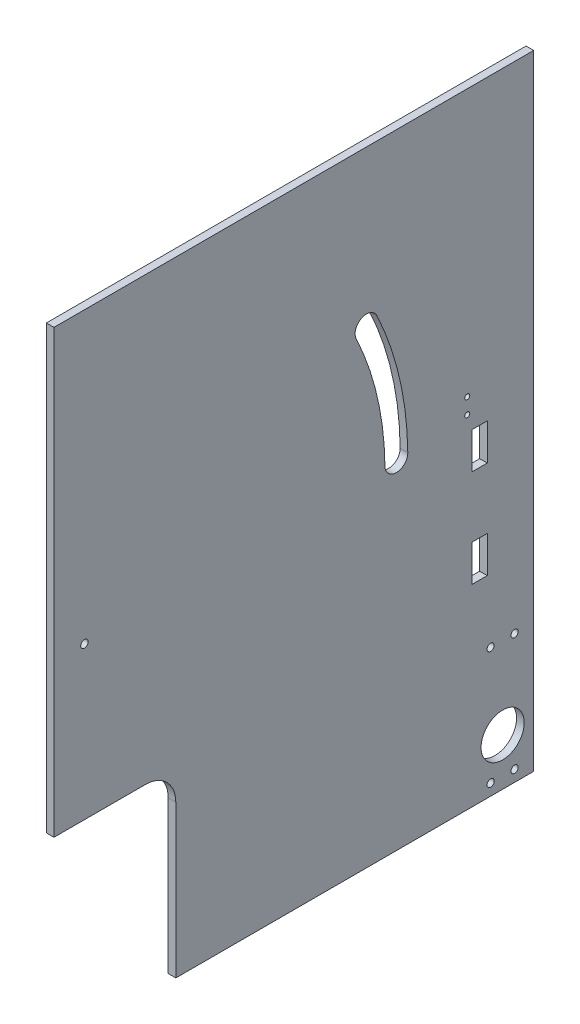
from build123d import *

# Parameters (mm, degrees)
SKETCH1_W           = 200.025
SKETCH1_H           = 260.35
BOSS_EXTRUDE1_DEPTH = 3.175
SKETCH8_R           = 1.55
SKETCH8_R_2         = 1.0499979
CUT_EXTRUDE7_DEPTH  = 4.175
SKETCH9_W           = 50.8
SKETCH9_H           = 76.2
CUT_EXTRUDE8_DEPTH  = 4.175
FILLET1_R           = 12.7
CUT_EXTRUDE9_DEPTH  = 4.175
SKETCH15_W          = 6.35
SKETCH15_H          = 15.24
CUT_EXTRUDE12_DEPTH = 4.175
SKETCH16_R          = 1.5
SKETCH16_R_2        = 9
CUT_EXTRUDE13_DEPTH = 4.175


with BuildPart() as part:
    # Sketch1 → Boss-Extrude1 (new body)
    with BuildSketch(Plane(origin=(0, 0, 0), x_dir=(0, 0, -1), z_dir=(1, 0, 0))):
        Rectangle(SKETCH1_W, SKETCH1_H)
    extrude(amount=BOSS_EXTRUDE1_DEPTH)

    # Sketch8 → Cut-Extrude7 (cut, through all)
    with BuildSketch(Plane.ZY):
        with Locations((87.3125, 9.525)):
            Circle(SKETCH8_R)
        with Locations((-72.3175, 18.9250066)):
            Circle(SKETCH8_R_2)
        with Locations((-72.3175, 12.4249942)):
            Circle(SKETCH8_R_2)
    extrude(amount=-CUT_EXTRUDE7_DEPTH, mode=Mode.SUBTRACT)

    # Sketch9 → Cut-Extrude8 (cut, through all)
    with BuildSketch(Plane.ZY):
        with Locations((74.6125, -92.075)):
            Rectangle(SKETCH9_W, SKETCH9_H)
    extrude(amount=-CUT_EXTRUDE8_DEPTH, mode=Mode.SUBTRACT)

    # Fillet1
    fillet1_edges = [part.edges().sort_by_distance(p)[0] for p in [
        (1.5875, -53.975, 49.2125),
    ]]
    fillet(fillet1_edges, radius=FILLET1_R)

    # Sketch10 → Cut-Extrude9 (cut, through all)
    with BuildSketch(Plane.ZY):
        with BuildLine():
            ThreePointArc((-34.631218673, 67.095364965), (-44.09213985, 39.8142402), (-47.528128749, 11.144346963))
            ThreePointArc((-47.528128749, 11.144346963), (-42.823162504, 6.325000001), (-38.003815542, 11.029966247))
            ThreePointArc((-38.003815542, 11.029966247), (-34.810523806, 37.674794334), (-26.017864022, 63.028948034))
            ThreePointArc((-26.017864022, 63.028948034), (-28.291332832, 69.36883393), (-34.631218673, 67.095364965))
        make_face()
    extrude(amount=-CUT_EXTRUDE9_DEPTH, mode=Mode.SUBTRACT)

    # Sketch15 → Cut-Extrude12 (cut, through all)
    with BuildSketch(Plane(origin=(3.175, 0, 0), x_dir=(0, 0, -1), z_dir=(1, 0, 0))):
        with Locations((77.4925, -1.5450058)):
            Rectangle(SKETCH15_W, SKETCH15_H)
        with Locations((77.4925, -42.1850058)):
            Rectangle(SKETCH15_W, SKETCH15_H)
    extrude(amount=-CUT_EXTRUDE12_DEPTH, mode=Mode.SUBTRACT)

    # Sketch16 → Cut-Extrude13 (cut, through all)
    with BuildSketch(Plane(origin=(3.175, 0, 0), x_dir=(0, 0, -1), z_dir=(1, 0, 0))):
        with Locations((82.075, -125.4125)):
            Circle(SKETCH16_R)
        with Locations((82.075, -76.4125)):
            Circle(SKETCH16_R)
        with Locations((92.075, -125.4125)):
            Circle(SKETCH16_R)
        with Locations((92.075, -76.4125)):
            Circle(SKETCH16_R)
        with Locations((87.075, -110.5624916)):
            Circle(SKETCH16_R_2)
    extrude(amount=-CUT_EXTRUDE13_DEPTH, mode=Mode.SUBTRACT)


solid = part.part
